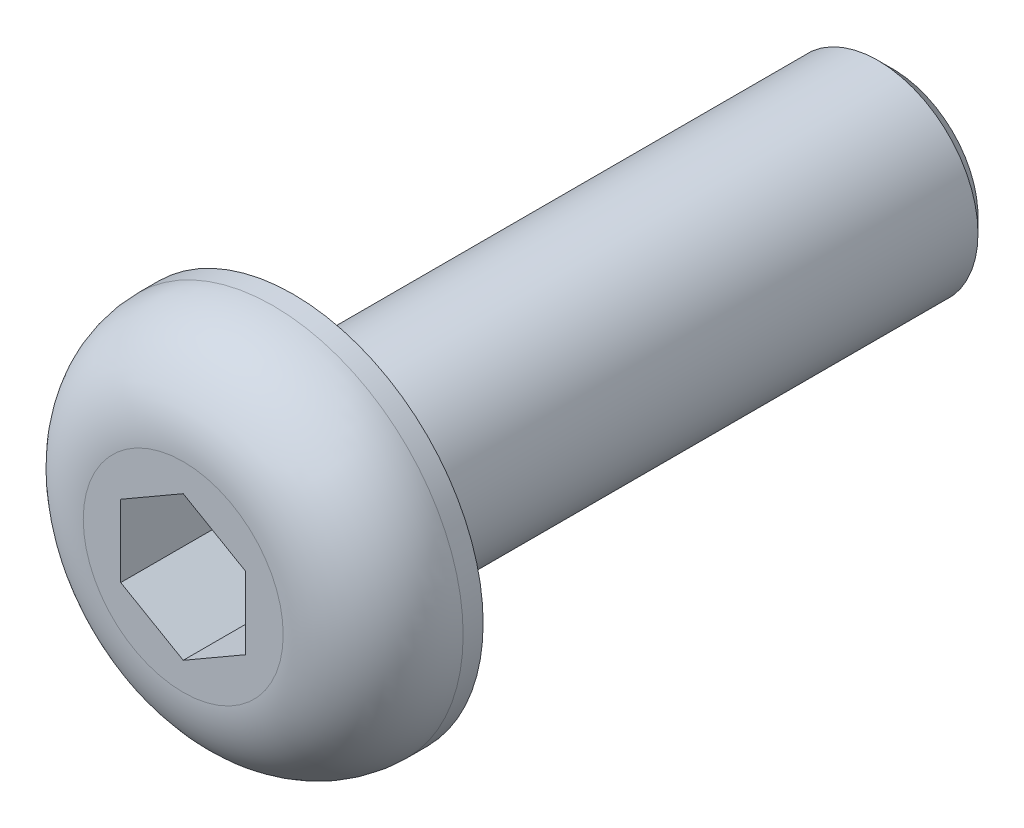
from build123d import *

# Parameters (mm, degrees)
SKETCH1_R           = 3.8
BOSS_EXTRUDE1_DEPTH = 2.2
SKETCH2_R           = 2
BOSS_EXTRUDE2_DEPTH = 12
CHAMFER1_SIZE       = 0.3
CUT_EXTRUDE1_DEPTH  = 2
FILLET1_R           = 1.8


with BuildPart() as part:
    # Sketch1 → Boss-Extrude1 (new body)
    with BuildSketch(Plane.XY):
        Circle(SKETCH1_R)
    extrude(amount=BOSS_EXTRUDE1_DEPTH)

    # Sketch2 → Boss-Extrude2 (add)
    with BuildSketch(Plane(origin=(0, 0, 0), x_dir=(-1, 0, 0), z_dir=(0, 0, -1))):
        Circle(SKETCH2_R)
    extrude(amount=BOSS_EXTRUDE2_DEPTH)

    # Chamfer1
    chamfer1_edges = [part.edges().sort_by_distance(p)[0] for p in [
        (2, 0, -12),
    ]]
    chamfer(chamfer1_edges, length=CHAMFER1_SIZE)

    # Sketch3 → Cut-Extrude1 (cut)
    with BuildSketch(Plane.XY.offset(2.2)):
        Polygon((0, 1.443375673), (-1.25, 0.721687836), (-1.25, -0.721687836), (0, -1.443375673), (1.25, -0.721687836), (1.25, 0.721687836), align=None)
    extrude(amount=-CUT_EXTRUDE1_DEPTH, mode=Mode.SUBTRACT)

    # Fillet1
    fillet1_edges = [part.edges().sort_by_distance(p)[0] for p in [
        (-3.8, 0, 2.2),
    ]]
    fillet(fillet1_edges, radius=FILLET1_R)


solid = part.part
